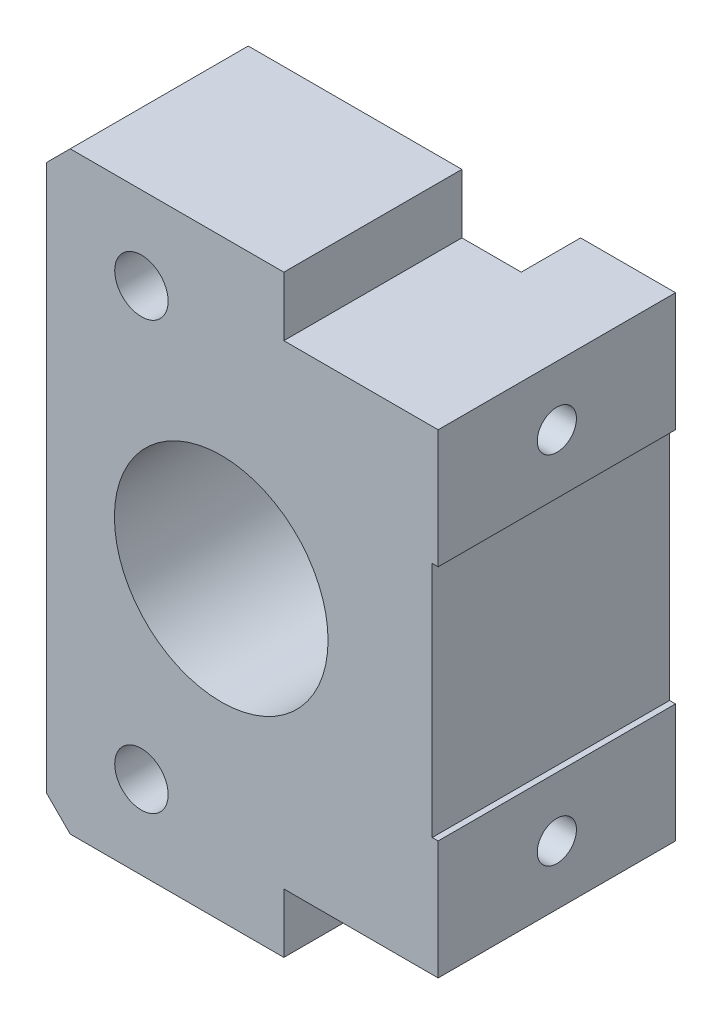
from build123d import *

# Parameters (mm, degrees)
SKETCH4_R             = 9
BOSS_EXTRUDE1_DEPTH   = 15
SKETCH5_R             = 4
CUT_EXTRUDE1_DEPTH    = 7
SKETCH6_R             = 2.25
CUT_EXTRUDE2_DEPTH    = 9
BOSS_EXTRUDE3_DEPTH   = 5
CHAMFER1_SIZE         = 2
M4_TAPPED_HOLE1_D     = 3.3
M4_TAPPED_HOLE1_DEPTH = 8
M4_TAPPED_HOLE1_TIP   = 0.991420021


with BuildPart() as part:
    # Sketch4 → Boss-Extrude1 (new body)
    with BuildSketch(Plane.XY):
        Polygon((-38.333333333, -25.277777778), (-38.333333333, 24.722222222), (-18.333333333, 24.722222222), (-18.333333333, 19.722222222), (-5.333333333, 19.722222222), (-5.333333333, 9.722222222), (-5.833333333, 9.722222222), (-5.833333333, -10.277777778), (-5.333333333, -10.277777778), (-5.333333333, -20.277777778), (-18.333333333, -20.277777778), (-18.333333333, -25.277777778), align=None)
        with Locations((-23.608519649, -0.277777778)):
            Circle(SKETCH4_R, mode=Mode.SUBTRACT)
    extrude(amount=BOSS_EXTRUDE1_DEPTH)

    # Sketch5 → Cut-Extrude1 (cut)
    with BuildSketch(Plane(origin=(0, 0, 0), x_dir=(-1, 0, 0), z_dir=(0, 0, -1))):
        with Locations((30.333333333, 17.722222222)):
            Circle(SKETCH5_R)
        with Locations((30.333333333, -18.277777778)):
            Circle(SKETCH5_R)
    extrude(amount=-CUT_EXTRUDE1_DEPTH, mode=Mode.SUBTRACT)

    # Sketch6 → Cut-Extrude2 (cut, through all)
    with BuildSketch(Plane(origin=(0, 0, 7), x_dir=(-1, 0, 0), z_dir=(0, 0, -1))):
        with Locations((30.333333333, 17.722222222)):
            Circle(SKETCH6_R)
        with Locations((30.333333333, -18.277777778)):
            Circle(SKETCH6_R)
    extrude(amount=-CUT_EXTRUDE2_DEPTH, mode=Mode.SUBTRACT)

    # Sketch9 → Boss-Extrude3 (add)
    with BuildSketch(Plane(origin=(0, 0, 0), x_dir=(-1, 0, 0), z_dir=(0, 0, -1))):
        Polygon((13.333333333, -20.277777778), (5.333333333, -20.277777778), (5.333333333, -10.277777778), (5.833333333, -10.277777778), (5.833333333, 9.722222222), (5.333333333, 9.722222222), (5.333333333, 19.722222222), (13.333333333, 19.722222222), align=None)
    extrude(amount=BOSS_EXTRUDE3_DEPTH)

    # Chamfer1
    chamfer1_edges = [part.edges().sort_by_distance(p)[0] for p in [
        (-38.333333333, -25.277777778, 7.5),
        (-38.333333333, 24.722222222, 7.5),
    ]]
    chamfer(chamfer1_edges, length=CHAMFER1_SIZE)

    # M4 Tapped Hole1
    with Locations(Plane(origin=(-5.333333333, 0, 0), x_dir=(0, 0, -1), z_dir=(1, 0, 0))):
        with Locations((-5, 14.722222222), (-5, -15.277777778)):
            Hole(M4_TAPPED_HOLE1_D / 2, depth=M4_TAPPED_HOLE1_DEPTH)
            with Locations((0, 0, -(M4_TAPPED_HOLE1_DEPTH + M4_TAPPED_HOLE1_TIP / 2))):  # 118° drill point
                Cone(0, M4_TAPPED_HOLE1_D / 2, M4_TAPPED_HOLE1_TIP, mode=Mode.SUBTRACT)


solid = part.part
